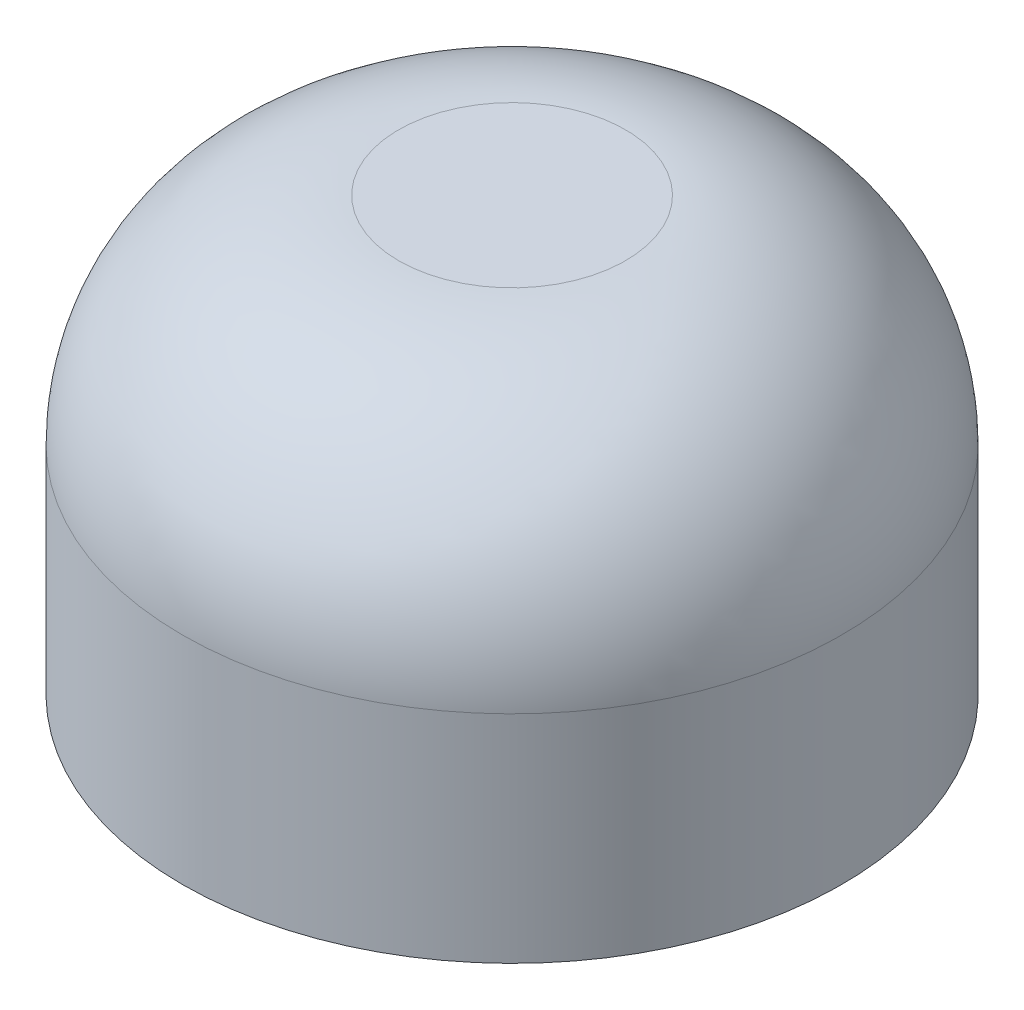
from build123d import *

# Parameters (mm, degrees)
SKETCH1_R           = 3.05
SKETCH1_R_2         = 1.55
BOSS_EXTRUDE1_DEPTH = 2
SKETCH3_R           = 3.05
BOSS_EXTRUDE2_DEPTH = 2
FILLET1_R           = 2


with BuildPart() as part:
    # Sketch1 → Boss-Extrude1 (new body)
    with BuildSketch(Plane(origin=(0, 0, 0), x_dir=(1, 0, 0), z_dir=(0, 1, 0))):
        Circle(SKETCH1_R)
        Circle(SKETCH1_R_2, mode=Mode.SUBTRACT)
    extrude(amount=BOSS_EXTRUDE1_DEPTH)

    # Sketch3 → Boss-Extrude2 (add)
    with BuildSketch(Plane(origin=(0, 2, 0), x_dir=(1, 0, 0), z_dir=(0, 1, 0))):
        Circle(SKETCH3_R)
    extrude(amount=BOSS_EXTRUDE2_DEPTH)

    # Fillet1
    fillet1_edges = [part.edges().sort_by_distance(p)[0] for p in [
        (-3.05, 4, 0),
    ]]
    fillet(fillet1_edges, radius=FILLET1_R)


solid = part.part
